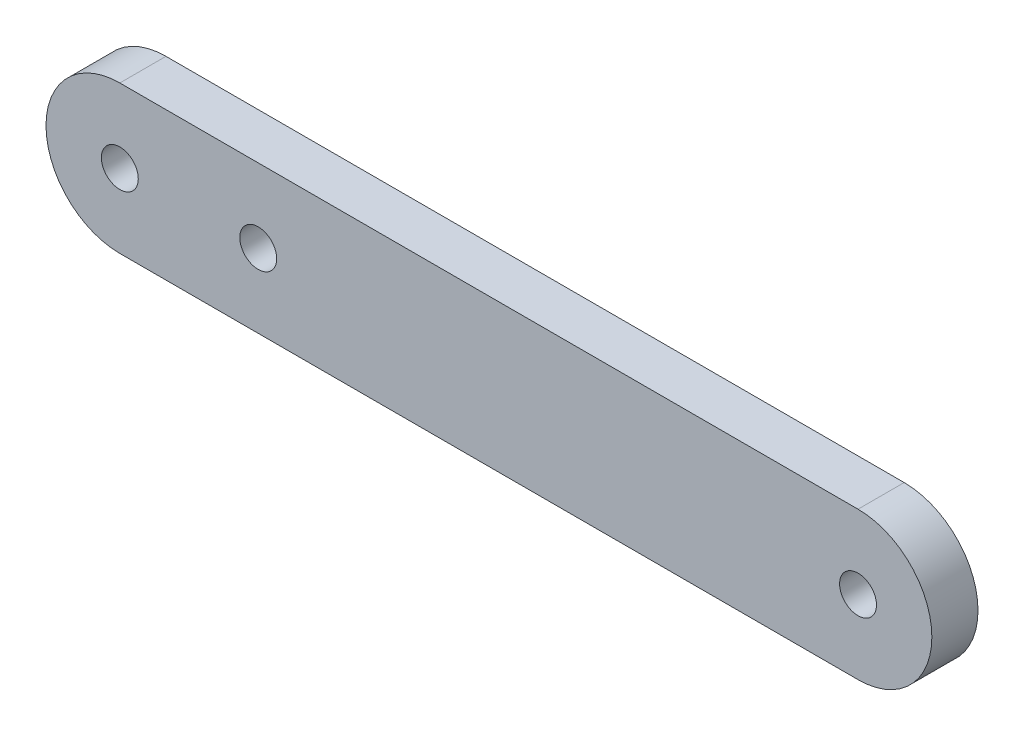
from build123d import *

# Parameters (mm, degrees)
SKETCH_1_R      = 2
EXTRUDE_1_DEPTH = 5


with BuildPart() as part:
    # 草图1 → 凸台-拉伸1 (new body)
    with BuildSketch(Plane.XY):
        with BuildLine():
            Line((-40, 8), (40, 8))
            ThreePointArc((40, 8), (48, 0), (40, -8))
            Line((40, -8), (-40, -8))
            ThreePointArc((-40, -8), (-48, 0), (-40, 8))
        make_face()
        with Locations((-40, 0)):
            Circle(SKETCH_1_R, mode=Mode.SUBTRACT)
        with Locations((40, 0)):
            Circle(SKETCH_1_R, mode=Mode.SUBTRACT)
        with Locations((-25, 0)):
            Circle(SKETCH_1_R, mode=Mode.SUBTRACT)
    extrude(amount=EXTRUDE_1_DEPTH)


solid = part.part
